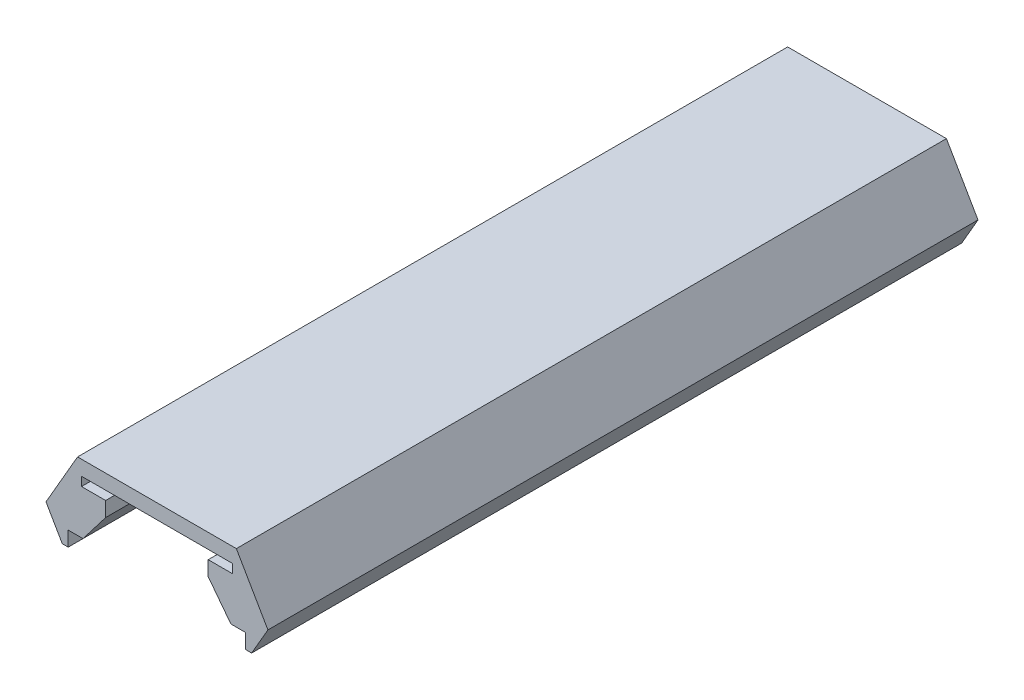
from build123d import *

# Parameters (mm, degrees)
BOSS_EXTRUDE1_DEPTH = 24


with BuildPart() as part:
    # Sketch2 → Boss-Extrude1 (new body, symmetric)
    with BuildSketch(Plane.XY):
        Polygon((7.5, -2.694744112), (5.366838493, 1), (-5.366838493, 1), (-7.5, -2.694744112), (-6.4, -4.6), (-6, -4.6), (-6, -3.6), (-5, -3.6), (-3.46692895, -1.6), (-3.46692895, -0.6), (-5.1, -0.6), (-5.1, 0), (5.1, 0), (5.1, -0.6), (3.46692895, -0.6), (3.46692895, -1.6), (5, -3.6), (6, -3.6), (6, -4.6), (6.4, -4.6), align=None)
    extrude(amount=BOSS_EXTRUDE1_DEPTH, both=True)


solid = part.part
